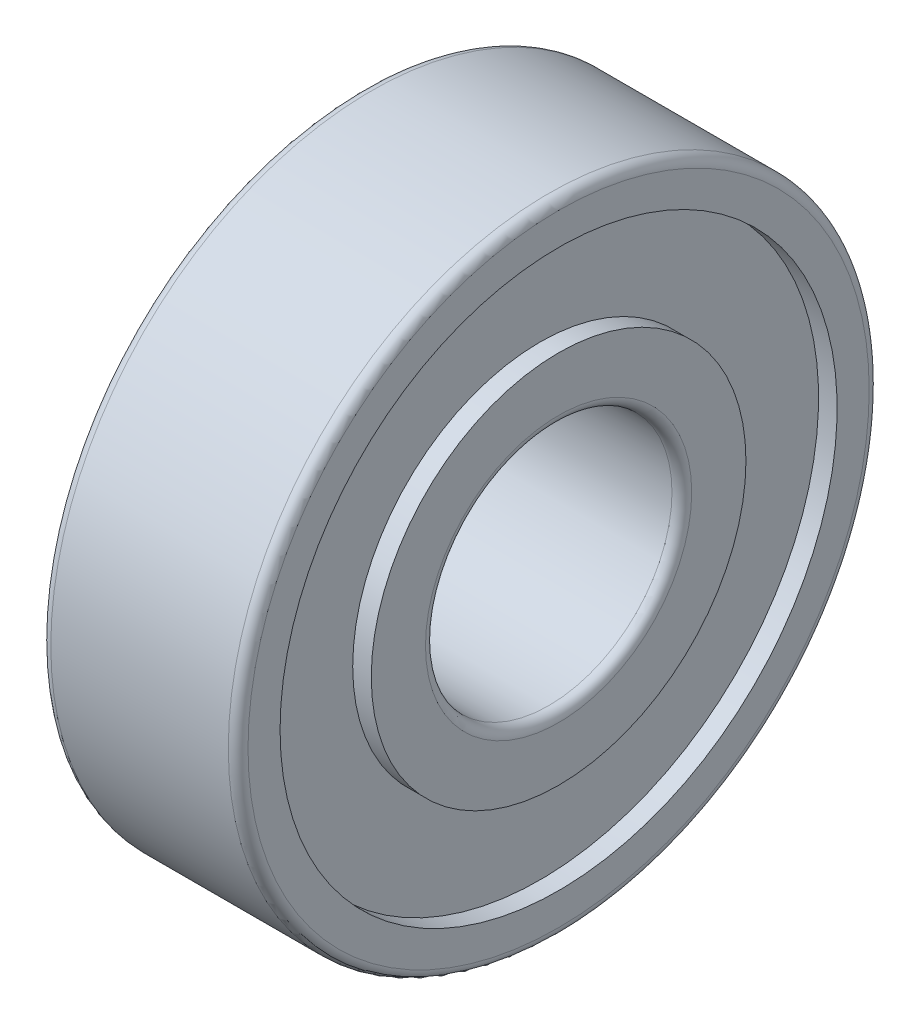
from build123d import *


with BuildPart() as part:
    # Sketch1 → Revolve1 (revolve)
    with BuildSketch(Plane.XY):
        with BuildLine():
            Line((0, 6.3), (0, 5.65))
            Line((0, 5.65), (0.3765, 5.65))
            Line((0.3765, 5.65), (0.3765, 3.8))
            Line((0.3765, 3.8), (0, 3.8))
            Line((0, 3.8), (0, 2.7))
            ThreePointArc((0, 2.7), (0.058578644, 2.558578644), (0.2, 2.5))
            Line((0.2, 2.5), (3.8, 2.5))
            ThreePointArc((3.8, 2.5), (3.941421356, 2.558578644), (4, 2.7))
            Line((4, 2.7), (4, 3.8))
            Line((4, 3.8), (3.6235, 3.8))
            Line((3.6235, 3.8), (3.6235, 5.65))
            Line((3.6235, 5.65), (4, 5.65))
            Line((4, 5.65), (4, 6.3))
            ThreePointArc((4, 6.3), (3.941421356, 6.441421356), (3.8, 6.5))
            Line((3.8, 6.5), (0.2, 6.5))
            ThreePointArc((0.2, 6.5), (0.058578644, 6.441421356), (0, 6.3))
        make_face()
    revolve(axis=Axis((3.8, 0, 0), (-1, 0, 0)))


solid = part.part
